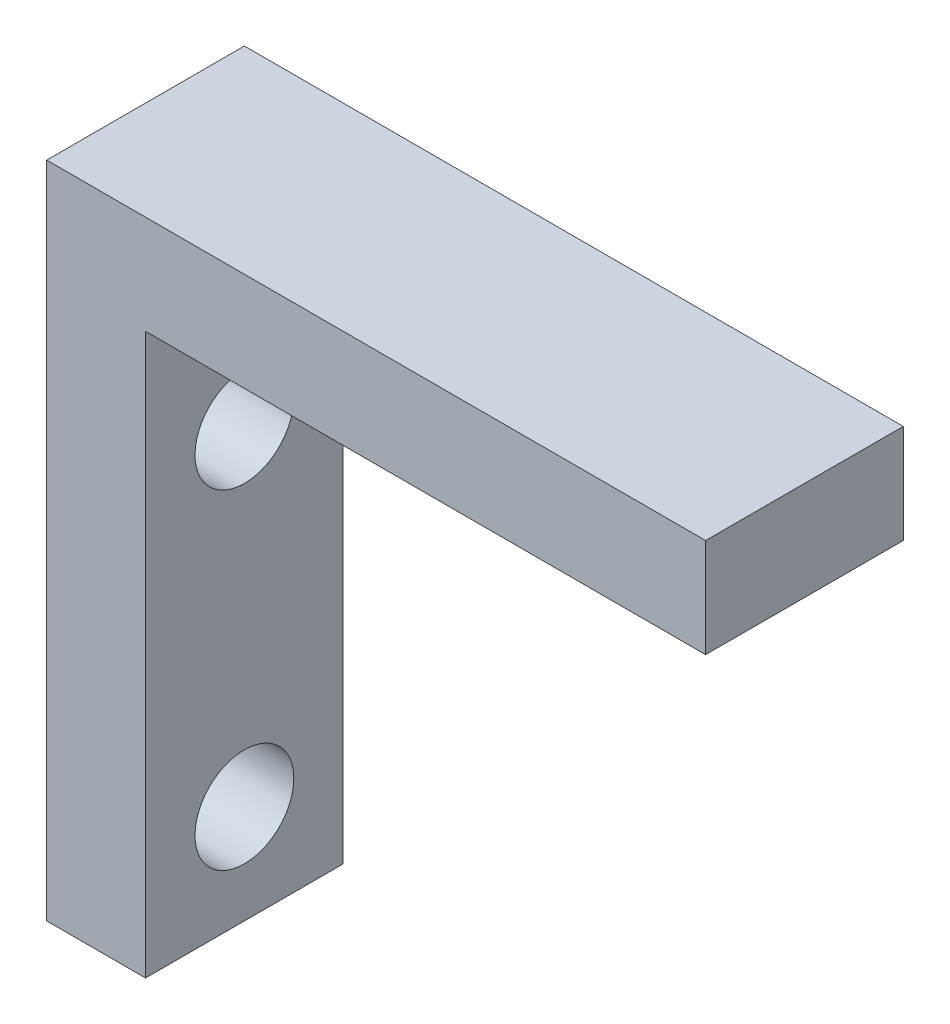
from build123d import *

# Parameters (mm, degrees)
BOSS_EXTRUDE1_DEPTH = 6
SKETCH4_R           = 1.5
CUT_EXTRUDE1_DEPTH  = 3


with BuildPart() as part:
    # Sketch1 → Boss-Extrude1 (new body)
    with BuildSketch(Plane.XY):
        Polygon((0, 0), (-20, 0), (-20, -20), (-17, -20), (-17, -3), (0, -3), align=None)
    extrude(amount=BOSS_EXTRUDE1_DEPTH)

    # Sketch4 → Cut-Extrude1 (cut)
    with BuildSketch(Plane.ZY.offset(20)):
        with Locations((3, -7)):
            Circle(SKETCH4_R)
        with Locations((3, -17)):
            Circle(SKETCH4_R)
    extrude(amount=-CUT_EXTRUDE1_DEPTH, mode=Mode.SUBTRACT)


solid = part.part
